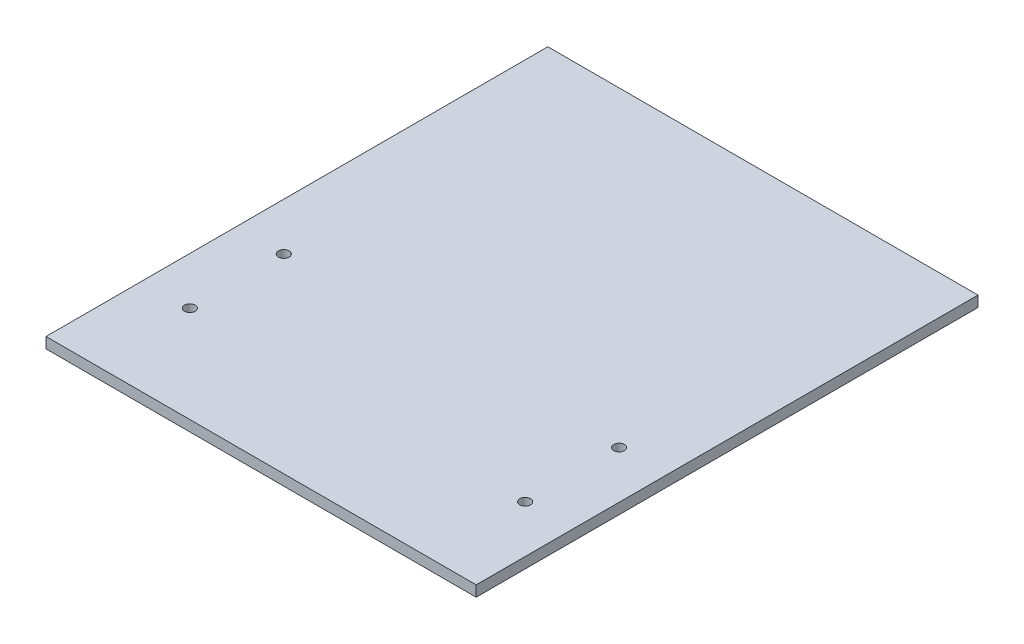
from build123d import *

# Parameters (mm, degrees)
SKETCH1_W           = 120
SKETCH1_H           = 140
BOSS_EXTRUDE1_DEPTH = 3
SKETCH2_R           = 1.5
CUT_EXTRUDE1_DEPTH  = 4


with BuildPart() as part:
    # Sketch1 → Boss-Extrude1 (new body)
    with BuildSketch(Plane(origin=(0, 0, 0), x_dir=(1, 0, 0), z_dir=(0, 1, 0))):
        Rectangle(SKETCH1_W, SKETCH1_H)
    extrude(amount=BOSS_EXTRUDE1_DEPTH)

    # Sketch2 → Cut-Extrude1 (cut, through all)
    with BuildSketch(Plane(origin=(0, 3, 0), x_dir=(1, 0, 0), z_dir=(0, 1, 0))):
        with Locations((-46.770246749, -16.9)):
            Circle(SKETCH2_R)
        with Locations((-46.770246749, -43.1)):
            Circle(SKETCH2_R)
        with Locations((46.770246749, -43.1)):
            Circle(SKETCH2_R)
        with Locations((46.770246749, -16.9)):
            Circle(SKETCH2_R)
    extrude(amount=-CUT_EXTRUDE1_DEPTH, mode=Mode.SUBTRACT)


solid = part.part
